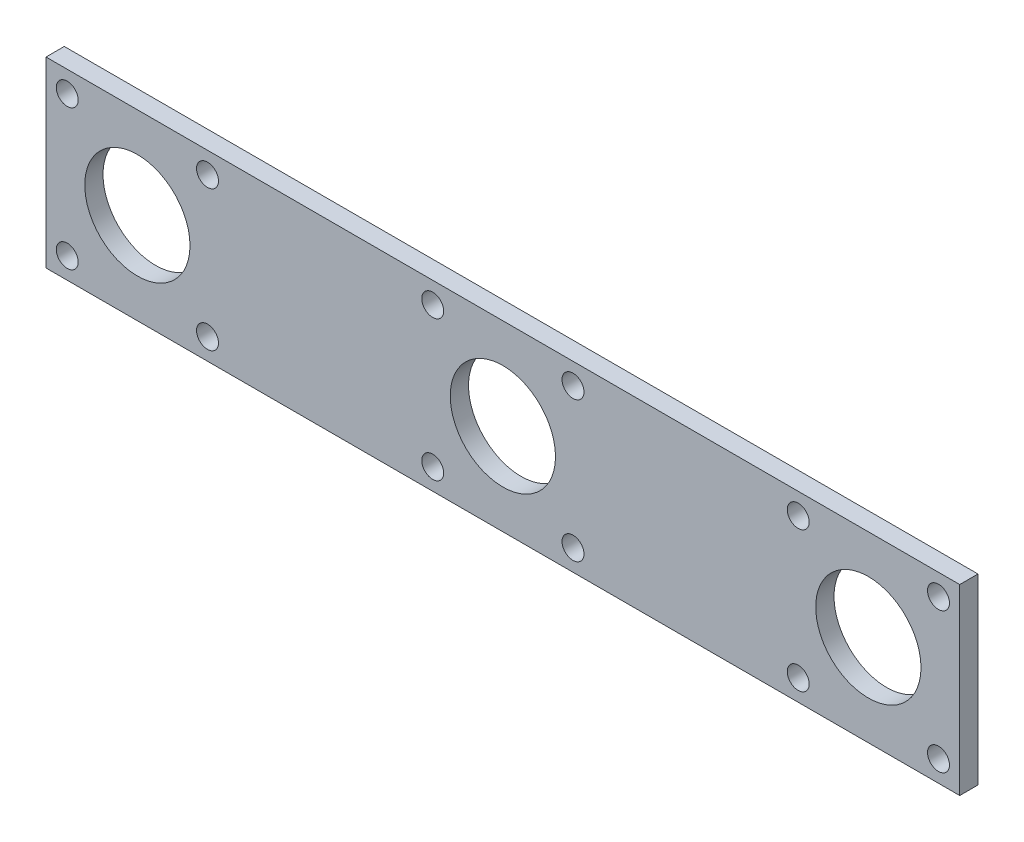
from build123d import *

# Parameters (mm, degrees)
SKETCH1_W           = 127
SKETCH1_H           = 25.4
SKETCH1_R           = 7.3152
SKETCH1_R_2         = 1.524
BOSS_EXTRUDE7_DEPTH = 2.54


with BuildPart() as part:
    # Sketch1 → Boss-Extrude7 (new body)
    with BuildSketch(Plane.XY):
        Rectangle(SKETCH1_W, SKETCH1_H)
        Circle(SKETCH1_R, mode=Mode.SUBTRACT)
        with Locations((9.748400853, 9.748400853)):
            Circle(SKETCH1_R_2, mode=Mode.SUBTRACT)
        with Locations((-9.748400853, -9.748400853)):
            Circle(SKETCH1_R_2, mode=Mode.SUBTRACT)
        with Locations((9.748400853, -9.748400853)):
            Circle(SKETCH1_R_2, mode=Mode.SUBTRACT)
        with Locations((-9.748400853, 9.748400853)):
            Circle(SKETCH1_R_2, mode=Mode.SUBTRACT)
        with Locations((50.8, 0)):
            Circle(SKETCH1_R, mode=Mode.SUBTRACT)
        with Locations((60.548400853, 9.748400853)):
            Circle(SKETCH1_R_2, mode=Mode.SUBTRACT)
        with Locations((41.051599147, -9.748400853)):
            Circle(SKETCH1_R_2, mode=Mode.SUBTRACT)
        with Locations((60.548400853, -9.748400853)):
            Circle(SKETCH1_R_2, mode=Mode.SUBTRACT)
        with Locations((41.051599147, 9.748400853)):
            Circle(SKETCH1_R_2, mode=Mode.SUBTRACT)
        with Locations((-50.8, 0)):
            Circle(SKETCH1_R, mode=Mode.SUBTRACT)
        with Locations((-41.051599147, 9.748400853)):
            Circle(SKETCH1_R_2, mode=Mode.SUBTRACT)
        with Locations((-60.548400853, -9.748400853)):
            Circle(SKETCH1_R_2, mode=Mode.SUBTRACT)
        with Locations((-41.051599147, -9.748400853)):
            Circle(SKETCH1_R_2, mode=Mode.SUBTRACT)
        with Locations((-60.548400853, 9.748400853)):
            Circle(SKETCH1_R_2, mode=Mode.SUBTRACT)
    extrude(amount=BOSS_EXTRUDE7_DEPTH)


solid = part.part
